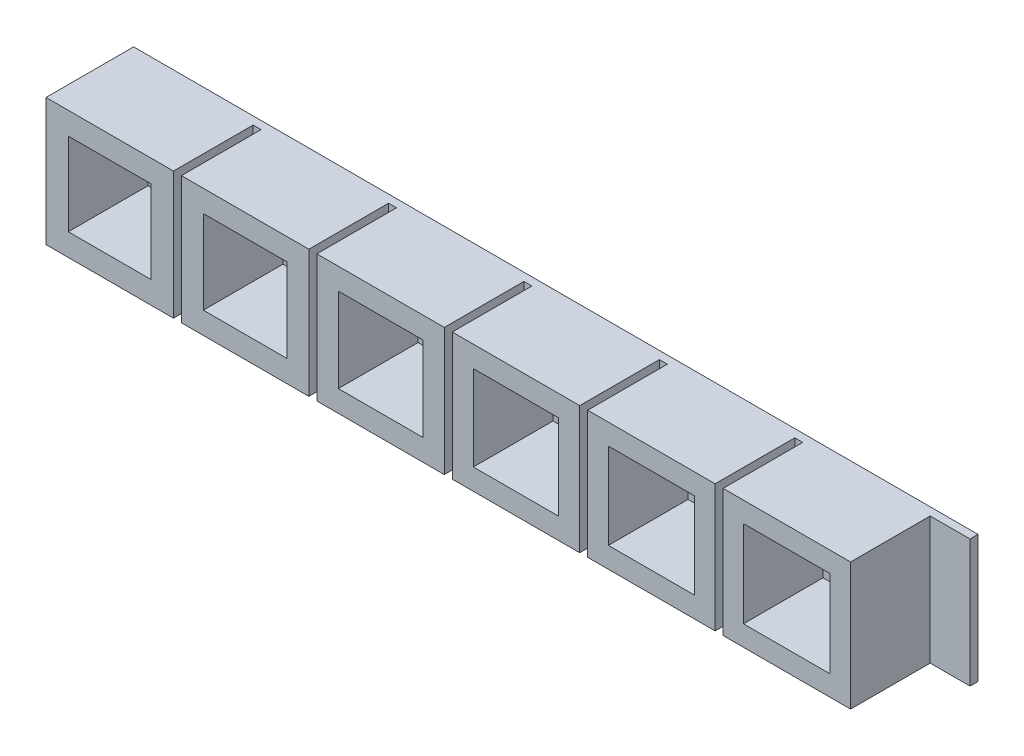
from build123d import *

# Parameters (mm, degrees)
SKETCH_1_W           = 106
SKETCH_1_H           = 16
EXTRUDE_1_DEPTH      = 11
SKETCH_2_W           = 5
SKETCH_2_H           = 10
CUT_EXTRUDE_1_DEPTH  = 17
SKETCH_3_W           = 1
SKETCH_3_H           = 10
CUT_EXTRUDE_2_DEPTH  = 17
SKETCH_4_W           = 1
SKETCH_4_H           = 10
CUT_EXTRUDE_3_DEPTH  = 17
SKETCH_5_W           = 1
SKETCH_5_H           = 10
CUT_EXTRUDE_4_DEPTH  = 17
SKETCH_6_W           = 1
SKETCH_6_H           = 10
CUT_EXTRUDE_5_DEPTH  = 17
SKETCH_7_W           = 1
SKETCH_7_H           = 10
CUT_EXTRUDE_6_DEPTH  = 17
SKETCH_8_W           = 10.4
SKETCH_8_H           = 10.4
CUT_EXTRUDE_7_DEPTH  = 10
SKETCH_9_W           = 10.5
SKETCH_9_H           = 10.5
CUT_EXTRUDE_8_DEPTH  = 10
SKETCH_10_W          = 10.6
SKETCH_10_H          = 10.6
CUT_EXTRUDE_9_DEPTH  = 10
SKETCH_11_W          = 10.7
SKETCH_11_H          = 10.7
CUT_EXTRUDE_10_DEPTH = 10
SKETCH_12_W          = 10.8
SKETCH_12_H          = 10.8
CUT_EXTRUDE_11_DEPTH = 10
SKETCH_13_W          = 10.9
SKETCH_13_H          = 10.9
CUT_EXTRUDE_12_DEPTH = 10


with BuildPart() as part:
    # 草图1 → 凸台-拉伸1 (new body)
    with BuildSketch(Plane(origin=(0, 0, 0), x_dir=(-1, 0, 0), z_dir=(0, 0, -1))):
        with Locations((-53, -28)):
            Rectangle(SKETCH_1_W, SKETCH_1_H)
    extrude(amount=-EXTRUDE_1_DEPTH)

    # 草图2 → 切除-拉伸1 (cut, through all)
    with BuildSketch(Plane(origin=(0, -20, 0), x_dir=(-1, 0, 0), z_dir=(0, 1, 0))):
        with Locations((-103.5, 6)):
            Rectangle(SKETCH_2_W, SKETCH_2_H)
    extrude(amount=-CUT_EXTRUDE_1_DEPTH, mode=Mode.SUBTRACT)

    # 草图3 → 切除-拉伸2 (cut, through all)
    with BuildSketch(Plane(origin=(0, -20, 0), x_dir=(-1, 0, 0), z_dir=(0, 1, 0))):
        with Locations((-84.5, 6)):
            Rectangle(SKETCH_3_W, SKETCH_3_H)
    extrude(amount=-CUT_EXTRUDE_2_DEPTH, mode=Mode.SUBTRACT)

    # 草图4 → 切除-拉伸3 (cut, through all)
    with BuildSketch(Plane(origin=(0, -20, 0), x_dir=(-1, 0, 0), z_dir=(0, 1, 0))):
        with Locations((-67.5, 6)):
            Rectangle(SKETCH_4_W, SKETCH_4_H)
    extrude(amount=-CUT_EXTRUDE_3_DEPTH, mode=Mode.SUBTRACT)

    # 草图5 → 切除-拉伸4 (cut, through all)
    with BuildSketch(Plane(origin=(0, -20, 0), x_dir=(-1, 0, 0), z_dir=(0, 1, 0))):
        with Locations((-50.5, 6)):
            Rectangle(SKETCH_5_W, SKETCH_5_H)
    extrude(amount=-CUT_EXTRUDE_4_DEPTH, mode=Mode.SUBTRACT)

    # 草图6 → 切除-拉伸5 (cut, through all)
    with BuildSketch(Plane(origin=(0, -20, 0), x_dir=(-1, 0, 0), z_dir=(0, 1, 0))):
        with Locations((-33.5, 6)):
            Rectangle(SKETCH_6_W, SKETCH_6_H)
    extrude(amount=-CUT_EXTRUDE_5_DEPTH, mode=Mode.SUBTRACT)

    # 草图7 → 切除-拉伸6 (cut, through all)
    with BuildSketch(Plane(origin=(0, -20, 0), x_dir=(-1, 0, 0), z_dir=(0, 1, 0))):
        with Locations((-16.5, 6)):
            Rectangle(SKETCH_7_W, SKETCH_7_H)
    extrude(amount=-CUT_EXTRUDE_6_DEPTH, mode=Mode.SUBTRACT)

    # 草图8 → 切除-拉伸7 (cut)
    with BuildSketch(Plane.XY.offset(11)):
        with Locations((8, -28)):
            Rectangle(SKETCH_8_W, SKETCH_8_H)
    extrude(amount=-CUT_EXTRUDE_7_DEPTH, mode=Mode.SUBTRACT)

    # 草图9 → 切除-拉伸8 (cut)
    with BuildSketch(Plane.XY.offset(11)):
        with Locations((25, -28)):
            Rectangle(SKETCH_9_W, SKETCH_9_H)
    extrude(amount=-CUT_EXTRUDE_8_DEPTH, mode=Mode.SUBTRACT)

    # 草图10 → 切除-拉伸9 (cut)
    with BuildSketch(Plane.XY.offset(11)):
        with Locations((42, -28)):
            Rectangle(SKETCH_10_W, SKETCH_10_H)
    extrude(amount=-CUT_EXTRUDE_9_DEPTH, mode=Mode.SUBTRACT)

    # 草图11 → 切除-拉伸10 (cut)
    with BuildSketch(Plane.XY.offset(11)):
        with Locations((59, -28)):
            Rectangle(SKETCH_11_W, SKETCH_11_H)
    extrude(amount=-CUT_EXTRUDE_10_DEPTH, mode=Mode.SUBTRACT)

    # 草图12 → 切除-拉伸11 (cut)
    with BuildSketch(Plane.XY.offset(11)):
        with Locations((76, -28)):
            Rectangle(SKETCH_12_W, SKETCH_12_H)
    extrude(amount=-CUT_EXTRUDE_11_DEPTH, mode=Mode.SUBTRACT)

    # 草图13 → 切除-拉伸12 (cut)
    with BuildSketch(Plane.XY.offset(11)):
        with Locations((93, -28)):
            Rectangle(SKETCH_13_W, SKETCH_13_H)
    extrude(amount=-CUT_EXTRUDE_12_DEPTH, mode=Mode.SUBTRACT)


solid = part.part
